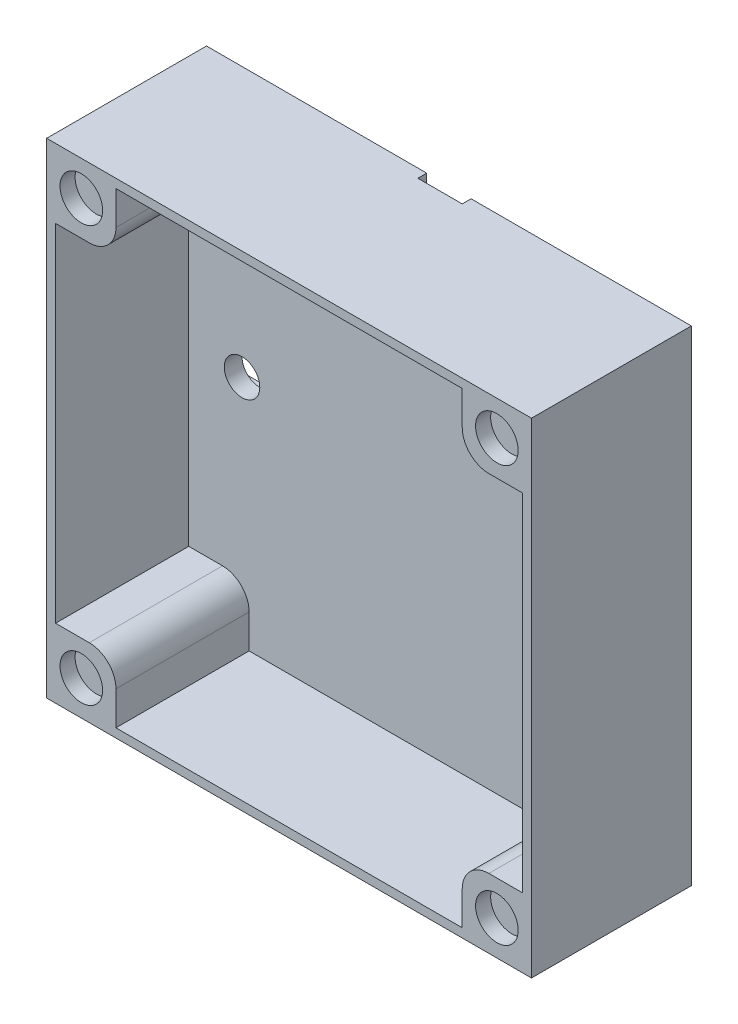
from build123d import *

# Parameters (mm, degrees)
SKICA1_W                 = 54.6
SKICA1_H                 = 54.6
P_IDAT_VYSUNUT_M2_DEPTH  = 3
SKICA5_W                 = 5
SKICA5_H                 = 24.8
ODEBRAT_VYSUNUT_M3_DEPTH = 1
SKICA14_W                = 52.6
SKICA14_H                = 1
P_IDAT_VYSUNUT_M9_DEPTH  = 15
SKICA17_R                = 2
ODEBRAT_VYSUNUT_M8_DEPTH = 7
SKICA19_W                = 7.8
SKICA19_H                = 7.8
P_IDAT_VYSUNUT_M10_DEPTH = 18
SKICA20_R                = 2.4
ODEBRAT_VYSUNUT_M9_DEPTH = 1.7
ZAOBLIT1_R               = 3
ZAOBLIT2_R               = 15
ZAOBLIT3_R               = 20


with BuildPart() as part:
    # Skica1 → Přidat vysunutím2 (new body)
    with BuildSketch(Plane.XY):
        Rectangle(SKICA1_W, SKICA1_H)
    extrude(amount=P_IDAT_VYSUNUT_M2_DEPTH)

    # Skica5 → Odebrat vysunutím3 (cut)
    with BuildSketch(Plane(origin=(0, 0, 0), x_dir=(-1, 0, 0), z_dir=(0, 0, -1))):
        with Locations((0, 14.9)):
            Rectangle(SKICA5_W, SKICA5_H)
        Polygon((27.3, 2.5), (2.5, 2.5), (-2.5, 2.5), (-2.5, -2.5), (27.3, -2.5), align=None)
    extrude(amount=-ODEBRAT_VYSUNUT_M3_DEPTH, mode=Mode.SUBTRACT)

    # Skica14 → Přidat vysunutím9 (add)
    with BuildSketch(Plane.XY.offset(3)):
        Polygon((27.3, 27.3), (-27.3, 27.3), (-27.3, -27.3), (-26.3, -27.3), (-26.3, -26.3), (-26.3, 26.3), (26.3, 26.3), (26.3, -26.3), (26.3, -27.3), (27.3, -27.3), align=None)
        with Locations((0, -26.8)):
            Rectangle(SKICA14_W, SKICA14_H)
    extrude(amount=P_IDAT_VYSUNUT_M9_DEPTH)

    # Skica17 → Odebrat vysunutím8 (cut)
    with BuildSketch(Plane(origin=(0, 0, 1), x_dir=(-1, 0, 0), z_dir=(0, 0, -1))):
        with Locations((20.3, 0)):
            Circle(SKICA17_R)
        with Locations((0, 20.3)):
            Circle(SKICA17_R)
    extrude(amount=-ODEBRAT_VYSUNUT_M8_DEPTH, mode=Mode.SUBTRACT)

    # Skica19 → Přidat vysunutím10 (add)
    with BuildSketch(Plane(origin=(0, 0, 0), x_dir=(-1, 0, 0), z_dir=(0, 0, -1))):
        with Locations((-23.4, 23.4)):
            Rectangle(SKICA19_W, SKICA19_H)
        with Locations((23.4, 23.4)):
            Rectangle(SKICA19_W, SKICA19_H)
        with Locations((-23.4, -23.4)):
            Rectangle(SKICA19_W, SKICA19_H)
        with Locations((23.4, -23.4)):
            Rectangle(SKICA19_W, SKICA19_H)
    extrude(amount=-P_IDAT_VYSUNUT_M10_DEPTH)

    # Skica20 → Odebrat vysunutím9 (cut)
    with BuildSketch(Plane.XY.offset(18)):
        with Locations((-23.4, -23.4)):
            Circle(SKICA20_R)
        with Locations((-23.4, 23.4)):
            Circle(SKICA20_R)
        with Locations((23.400280565, 23.4)):
            Circle(SKICA20_R)
        with Locations((23.400280565, -23.4)):
            Circle(SKICA20_R)
    extrude(amount=-ODEBRAT_VYSUNUT_M9_DEPTH, mode=Mode.SUBTRACT)

    # Zaoblit1
    zaoblit1_edges = [part.edges().sort_by_distance(p)[0] for p in [
        (-19.5, 19.5, 10.5),
        (19.5, -19.5, 10.5),
        (-19.5, -19.5, 10.5),
        (19.5, 19.5, 10.5),
    ]]
    fillet(zaoblit1_edges, radius=ZAOBLIT1_R)

    # Zaoblit2
    zaoblit2_edges = [part.edges().sort_by_distance(p)[0] for p in [
        (-2.5, 2.5, 0.5),
    ]]
    fillet(zaoblit2_edges, radius=ZAOBLIT2_R)

    # Zaoblit3
    zaoblit3_edges = [part.edges().sort_by_distance(p)[0] for p in [
        (2.5, -2.5, 0.5),
    ]]
    fillet(zaoblit3_edges, radius=ZAOBLIT3_R)


solid = part.part
